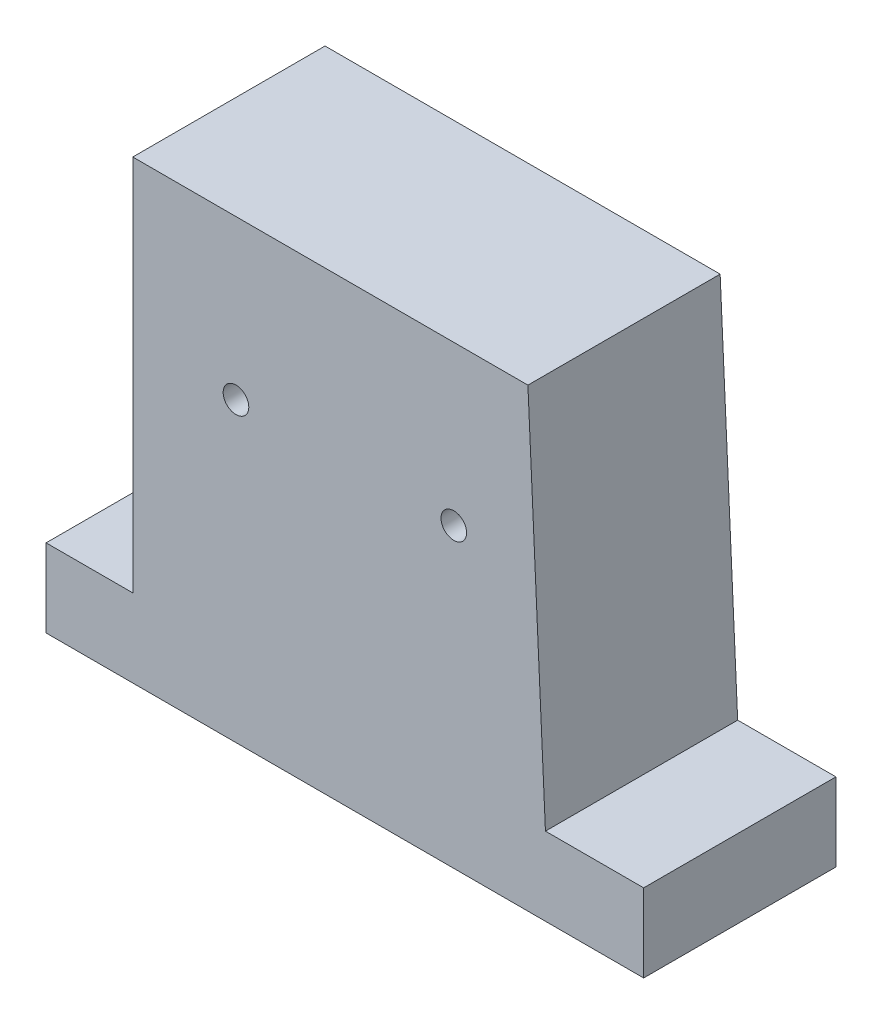
from build123d import *

# Parameters (mm, degrees)
SKETCH1_R           = 4
BOSS_EXTRUDE1_DEPTH = 60


with BuildPart() as part:
    # Sketch1 → Boss-Extrude1 (new body)
    with BuildSketch(Plane.XY):
        Polygon((-78.477343622, -6.715827259), (-105.53442836, -6.715827259), (-105.53442836, -31.084686171), (-55.837306641, -31.084686171), (31.27656695, -31.084686171), (80.973688669, -31.084686171), (80.973688669, -6.715827259), (50.315337096, -6.715827259), (44.843773057, 111.105741969), (-78.477343622, 111.105741969), align=None)
        with Locations((-46.271365908, 61.586520729)):
            Circle(SKETCH1_R, mode=Mode.SUBTRACT)
        with Locations((21.710626217, 61.586520729)):
            Circle(SKETCH1_R, mode=Mode.SUBTRACT)
    extrude(amount=BOSS_EXTRUDE1_DEPTH)


solid = part.part
